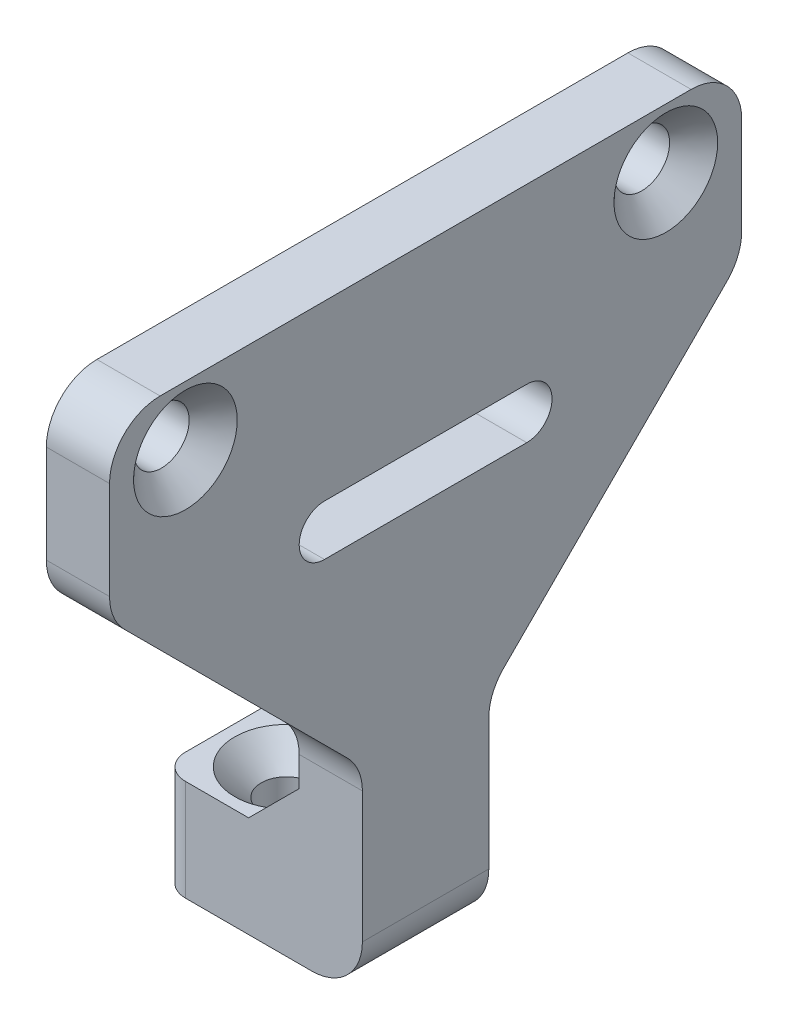
from build123d import *

# Parameters (mm, degrees)
SKETCH_1_W                   = 25
SKETCH_1_H                   = 4.7
SKETCH_1_R                   = 1.1
EXTRUDE_1_DEPTH              = 2.5
HOLE_WIZARD_M2_1_D           = 2
HOLE_WIZARD_M2_1_CSINK_D     = 4.1
HOLE_WIZARD_M2_1_CSINK_ANGLE = 90
EXTRUDE_2_DEPTH              = 2.5
SKETCH1_R                    = 0.85
EXTRUDE1_DEPTH               = 10
SKETCH3_R                    = 2.05
EXTRUDE2_DEPTH               = 10
EXTRUDE4_DEPTH               = 2.5
EXTRUDE5_DEPTH               = 10
FILLET1_R                    = 2
FILLET2_R                    = 1
FILLET3_R                    = 2


with BuildPart() as part:
    # 草图1 → 凸台-拉伸1 (new body)
    with BuildSketch(Plane(origin=(0, 0, 0), x_dir=(0, 0, -1), z_dir=(1, 0, 0))):
        Rectangle(SKETCH_1_W, SKETCH_1_H)
        with Locations((9.5, 0)):
            Circle(SKETCH_1_R, mode=Mode.SUBTRACT)
        with Locations((-9.5, 0)):
            Circle(SKETCH_1_R, mode=Mode.SUBTRACT)
    extrude(amount=EXTRUDE_1_DEPTH)

    # M2 平头机械螺钉的锥形沉头孔1 (through all)
    with Locations(Plane(origin=(2.5, 0, 9.5), x_dir=(0, 0, 1), z_dir=(1, 0, 0))):
        with Locations((0, 0), (-19, 0)):
            CounterSinkHole(HOLE_WIZARD_M2_1_D / 2, HOLE_WIZARD_M2_1_CSINK_D / 2, counter_sink_angle=HOLE_WIZARD_M2_1_CSINK_ANGLE)

    # 草图3 → 凸台-拉伸2 (add, symmetric)
    with BuildSketch(Plane.XY):
        Polygon((0, -2.35), (2.5, -2.35), (2.5, -22.35), (-5.5, -22.35), (-5.5, -18.35), (-2, -18.35), (0, -16.35), align=None)
    extrude(amount=EXTRUDE_2_DEPTH, both=True)

    # Sketch1 → Extrude1 (cut)
    with BuildSketch(Plane(origin=(0, -18.35, 0), x_dir=(1, 0, 0), z_dir=(0, 1, 0))):
        with Locations(Location((-3, 0, 0), (0, 0, 270))):  # turned: the seam where the file's is
            Circle(SKETCH1_R)
    extrude(amount=-EXTRUDE1_DEPTH, mode=Mode.SUBTRACT)

    # Sketch2 → CSK for M2 Flat Head Machine Screw1 (revolve, cut)
    with BuildSketch(Plane(origin=(-3, -18.35, 0), x_dir=(0, 0, 1), z_dir=(1, 0, 0))):
        Polygon((0, 0), (0, 4.000025), (1, 4.000025), (1, 1.05), (2.05, 0), align=None)
    revolve(axis=Axis((-3, -12, 0), (0, -1, 0)), mode=Mode.SUBTRACT)

    # Sketch3 → Extrude2 (cut)
    with BuildSketch(Plane(origin=(0, -18.35, 0), x_dir=(1, 0, 0), z_dir=(0, 1, 0))):
        with Locations((-3, 0)):
            Circle(SKETCH3_R)
    extrude(amount=EXTRUDE2_DEPTH, mode=Mode.SUBTRACT)

    # Sketch6 → Extrude4 (add)
    with BuildSketch(Plane(origin=(2.5, 0, 0), x_dir=(0, 0, -1), z_dir=(1, 0, 0))):
        Polygon((-12.5, -2.35), (-2.5, -2.35), (-2.5, -14.35), (-12.5, -4.35), align=None)
        Polygon((12.5, -4.35), (12.5, -2.35), (2.5, -2.35), (2.5, -14.35), align=None)
    extrude(amount=-EXTRUDE4_DEPTH)

    # Sketch7 → Extrude5 (cut)
    with BuildSketch(Plane(origin=(2.5, 0, 0), x_dir=(0, 0, -1), z_dir=(1, 0, 0))):
        with BuildLine():
            Line((-4, -4.5), (4, -4.5))
            ThreePointArc((4, -4.5), (5, -5.5), (4, -6.5))
            Line((4, -6.5), (-4, -6.5))
            ThreePointArc((-4, -6.5), (-5, -5.5), (-4, -4.5))
        make_face()
    extrude(amount=-EXTRUDE5_DEPTH, mode=Mode.SUBTRACT)

    # Fillet1
    fillet1_edges = [part.edges().sort_by_distance(p)[0] for p in [
        (1.25, -4.35, -12.5),
        (1.25, -14.35, -2.5),
        (1.25, -14.35, 2.5),
        (1.25, -4.35, 12.5),
        (1.25, 2.35, -12.5),
        (1.25, 2.35, 12.5),
    ]]
    fillet(fillet1_edges, radius=FILLET1_R)

    # Fillet2
    fillet2_edges = [part.edges().sort_by_distance(p)[0] for p in [
        (-5.5, -20.35, -2.5),
        (-5.5, -20.35, 2.5),
    ]]
    fillet(fillet2_edges, radius=FILLET2_R)

    # Fillet3
    fillet3_edges = [part.edges().sort_by_distance(p)[0] for p in [
        (2.5, -22.35, 0),
    ]]
    fillet(fillet3_edges, radius=FILLET3_R)


solid = part.part
